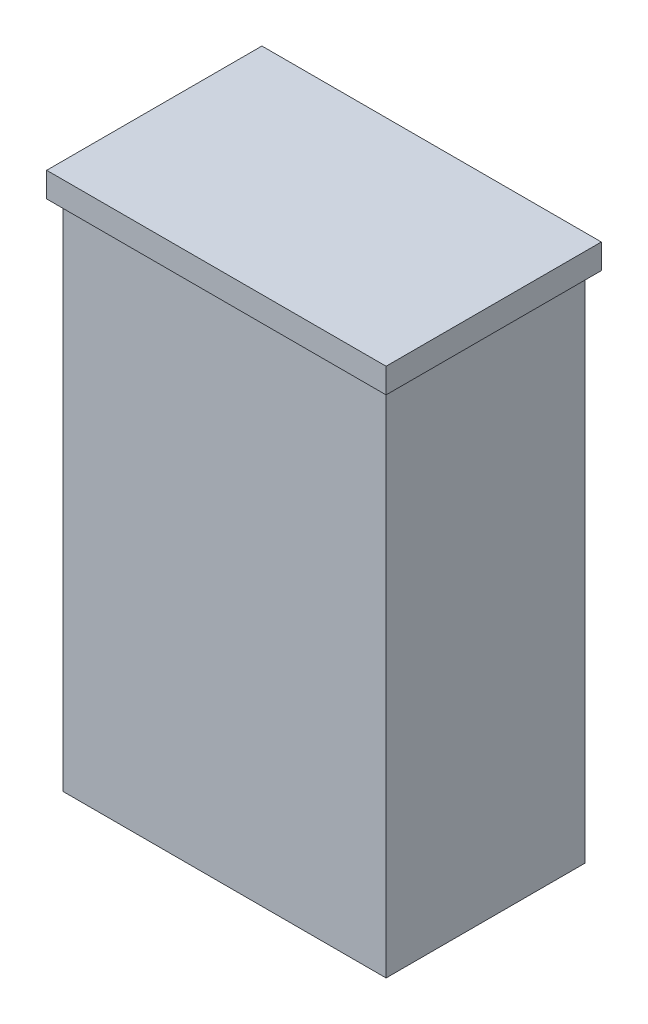
from build123d import *

# Parameters (mm, degrees)
SCHIZZO1_W                   = 39
SCHIZZO1_H                   = 24
ESTRUSIONE_ESTRUSIONE1_DEPTH = 62
SCHIZZO2_W                   = 41
SCHIZZO2_H                   = 26
ESTRUSIONE_ESTRUSIONE2_DEPTH = 3


with BuildPart() as part:
    # Schizzo1 → Estrusione-Estrusione1 (new body)
    with BuildSketch(Plane(origin=(0, 0, 0), x_dir=(1, 0, 0), z_dir=(0, 1, 0))):
        Rectangle(SCHIZZO1_W, SCHIZZO1_H)
    extrude(amount=ESTRUSIONE_ESTRUSIONE1_DEPTH)

    # Schizzo2 → Estrusione-Estrusione2 (add)
    with BuildSketch(Plane(origin=(0, 62, 0), x_dir=(1, 0, 0), z_dir=(0, 1, 0))):
        Rectangle(SCHIZZO2_W, SCHIZZO2_H)
    extrude(amount=ESTRUSIONE_ESTRUSIONE2_DEPTH)


solid = part.part
